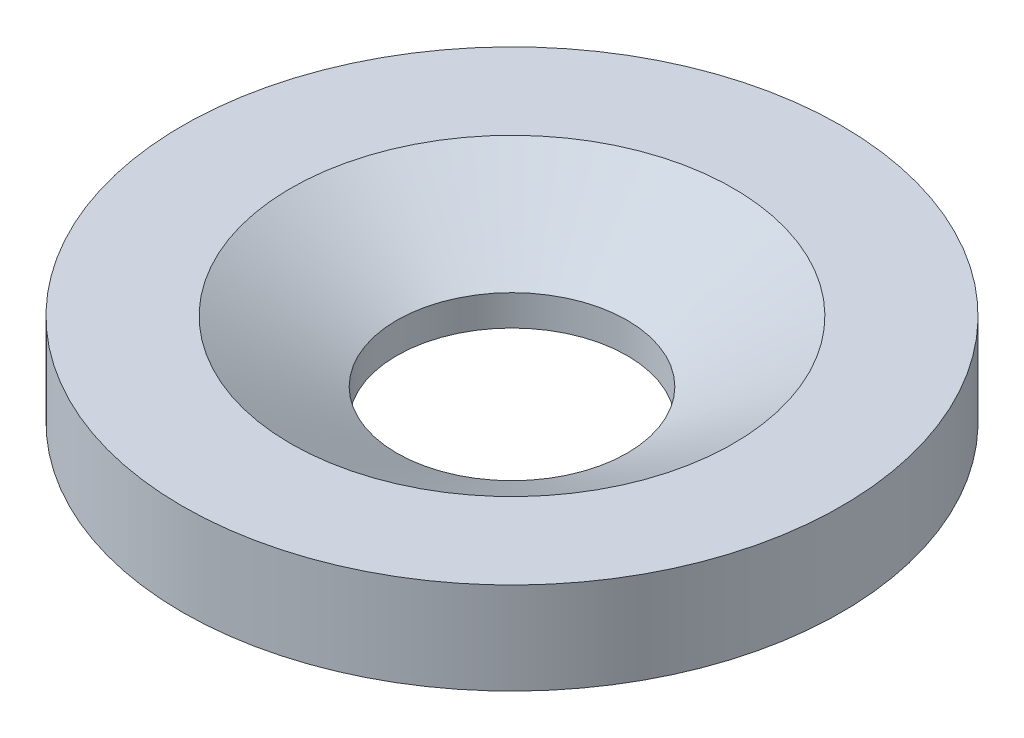
from build123d import *


with BuildPart() as part:
    # Sketch1 → Revolve1 (revolve)
    with BuildSketch(Plane.XY):
        Polygon((47.752, 0), (47.752, 12.7), (91.746090512, 38.1), (136.652, 38.1), (136.652, 0), align=None)
    revolve(axis=Axis((0, 36.544130423, 0), (0, -1, 0)))


solid = part.part
